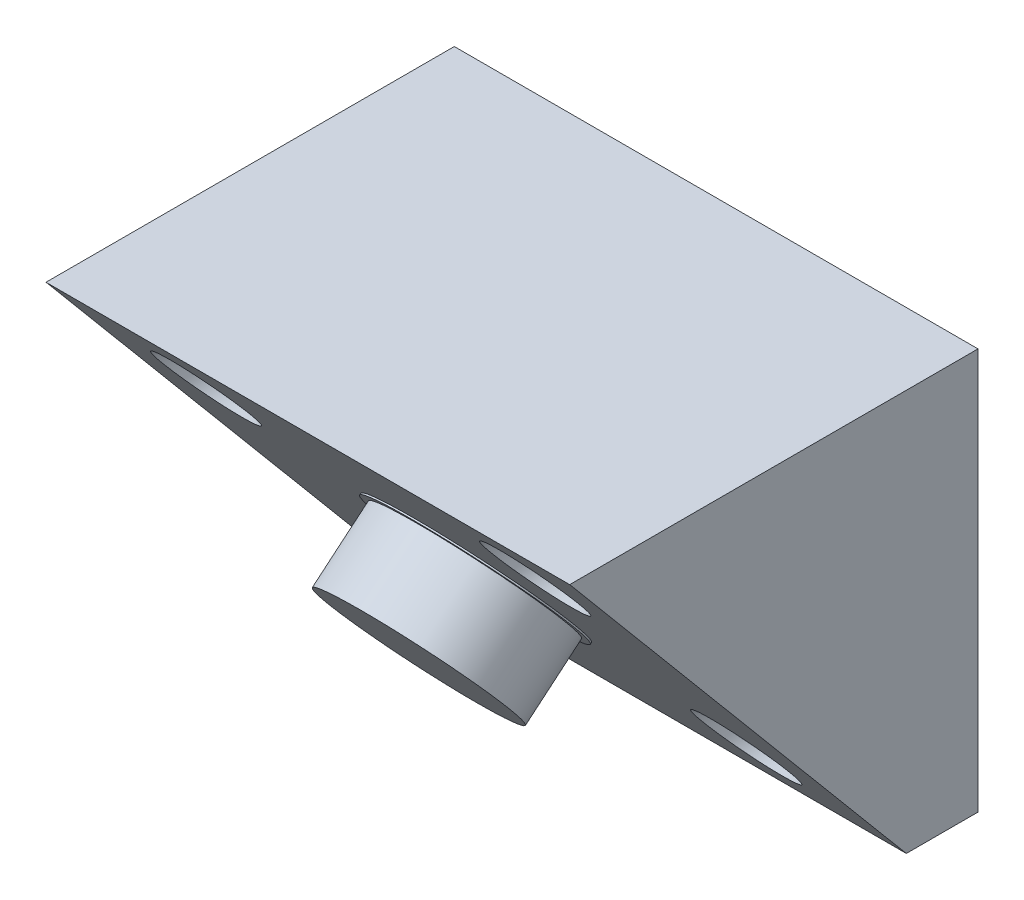
from build123d import *

# Parameters (mm, degrees)
AUFSATZ_LINEAR_AUSTRAGEN1_DEPTH      = 35
SKIZZE3_R                            = 6
AUFSATZ_LINEAR_AUSTRAGEN2_DEPTH      = 5
SKIZZE4_R                            = 6.5
AUFSATZ_LINEAR_AUSTRAGEN3_DEPTH      = 0.1
SKIZZE7_R                            = 2.85
SCHNITT_LINEAR_AUSTRAGEN1_DEPTH      = 23.497566339
F_3_4_3_4_DURCHMESSER_BOHRUNG1_D     = 3.4
F_3_4_3_4_DURCHMESSER_BOHRUNG1_DEPTH = 4.79
K_RPER_VERSCHIEBEN_KOPIEREN1_ANGLE   = 90


with BuildPart() as part:
    # Skizze1 → Aufsatz-Linear austragen1 (new body)
    with BuildSketch(Plane(origin=(0, 0, 0), x_dir=(0, 0, -1), z_dir=(1, 0, 0))):
        Polygon((0, 0), (26.811555509, 0), (26.811555509, 27.287566339), (0, 4.79), align=None)
    extrude(amount=AUFSATZ_LINEAR_AUSTRAGEN1_DEPTH)

    # Skizze3 → Aufsatz-Linear austragen2 (add)
    with BuildSketch(Plane(origin=(0, 2.810887386, 2.358614568), x_dir=(1, 0, 0), z_dir=(0, 0.766044443, 0.64278761))):
        with Locations((17.5, 20.57895265)):
            Circle(SKIZZE3_R)
    extrude(amount=AUFSATZ_LINEAR_AUSTRAGEN2_DEPTH)

    # Skizze4 → Aufsatz-Linear austragen3 (add)
    with BuildSketch(Plane(origin=(0, 2.810887386, 2.358614568), x_dir=(1, 0, 0), z_dir=(0, 0.766044443, 0.64278761))):
        with Locations((17.5, 20.57895265)):
            Circle(SKIZZE4_R)
    extrude(amount=AUFSATZ_LINEAR_AUSTRAGEN3_DEPTH)

    # Skizze7 → Schnitt-Linear austragen1 (cut, through all)
    with BuildSketch(Plane(origin=(0, 4.79, 0), x_dir=(-1, 0, 0), z_dir=(0, -1, 0))):
        with Locations((-28.5, 21.811555509)):
            Circle(SKIZZE7_R)
        with Locations((-6.5, 21.811555509)):
            Circle(SKIZZE7_R)
        with Locations((-6.5, 5)):
            Circle(SKIZZE7_R)
        with Locations((-28.5, 5)):
            Circle(SKIZZE7_R)
    extrude(amount=-SCHNITT_LINEAR_AUSTRAGEN1_DEPTH, mode=Mode.SUBTRACT)

    # Ø3.4 (3.4) Durchmesser Bohrung1
    with Locations(Plane(origin=(6.5, 4.79, -21.811555509), x_dir=(0, 0, 1), z_dir=(0, 1, 0))):
        with Locations((0, 0), (16.811555509, 0), (16.811555509, 22), (0, 22)):
            Hole(F_3_4_3_4_DURCHMESSER_BOHRUNG1_D / 2, depth=F_3_4_3_4_DURCHMESSER_BOHRUNG1_DEPTH)


with BuildPart() as part_1:
    # Körper-Verschieben/Kopieren1: moved
    add(part.part.rotate(Axis((0, 13.64378317, -13.405777755), (1, 0, 0)), K_RPER_VERSCHIEBEN_KOPIEREN1_ANGLE))


solid = part_1.part
